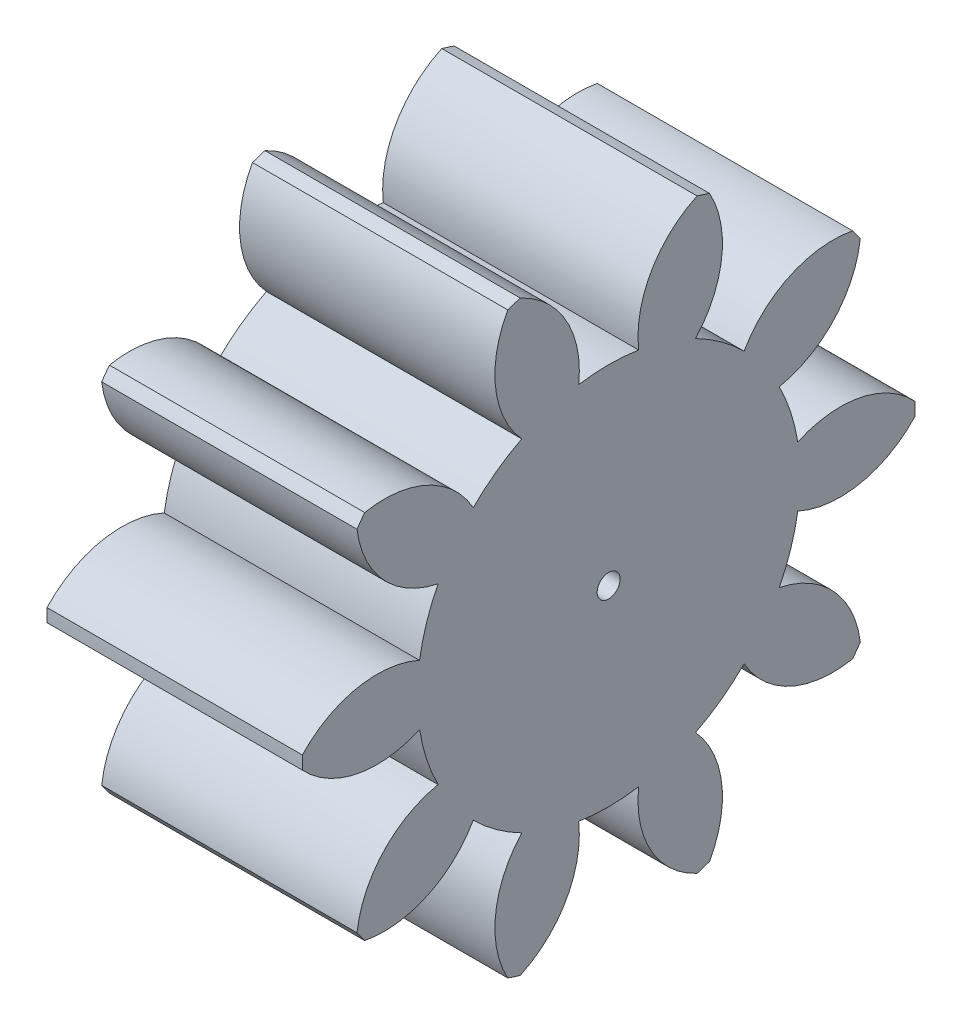
from build123d import *

# Parameters (mm, degrees)
BASPROSKE_W     = 10
BASPROSKE_H     = 12
TOOTHCUT_DEPTH  = 20.697715604
TEETHCUTS_COUNT = 10
TEETHCUTS_ANGLE = 324
BORSKE_R        = 0.45
BORE_DEPTH      = 50.0000508


with BuildPart() as part:
    # BasProSke → Base-Revolve (revolve)
    with BuildSketch(Plane(origin=(0, 0, 0), x_dir=(1, 0, 0), z_dir=(0, 1, 0)), mode=Mode.PRIVATE) as base_revolve_sk:
        with Locations((5, 6)):
            Rectangle(BASPROSKE_W, BASPROSKE_H)
    revolve(base_revolve_sk.sketch.rotate(Axis((-10, 0, 0), (1, 0, 0)), 180), axis=Axis((-10, 0, 0), (1, 0, 0)))

    # TooCutSke → ToothCut (cut, through all)
    with BuildSketch(Plane(origin=(0, 0, 0), x_dir=(0, 0, -1), z_dir=(1, 0, 0))):
        with BuildLine():
            ThreePointArc((1.173662691, 7.406586048), (0, 7.499), (-1.173662691, 7.406586048))
            ThreePointArc((-1.173662691, 7.406586048), (-1.668191438, 9.834565786), (-3.497907776, 11.50542856))
            ThreePointArc((-3.497907776, 11.50542856), (0, 12.0254), (3.497907776, 11.50542856))
            ThreePointArc((3.497907776, 11.50542856), (1.668191438, 9.834565786), (1.173662691, 7.406586048))
        make_face()
    toothcut = extrude(amount=TOOTHCUT_DEPTH, mode=Mode.SUBTRACT)

    # TeethCuts: ToothCut ×10 about axis
    teethcuts_axis = Axis((-10, 0, 0), (1, 0, 0))
    for i in range(1, TEETHCUTS_COUNT):
        add(toothcut.rotate(teethcuts_axis, i * TEETHCUTS_ANGLE / (TEETHCUTS_COUNT - 1)), mode=Mode.SUBTRACT)

    # BorSke → Bore (cut, symmetric)
    with BuildSketch(Plane(origin=(0, 0, 0), x_dir=(0, 0, -1), z_dir=(1, 0, 0))):
        with Locations(Location((0, 0, 0), (0, 0, 180))):
            Circle(BORSKE_R)
    extrude(amount=BORE_DEPTH, both=True, mode=Mode.SUBTRACT)


solid = part.part
